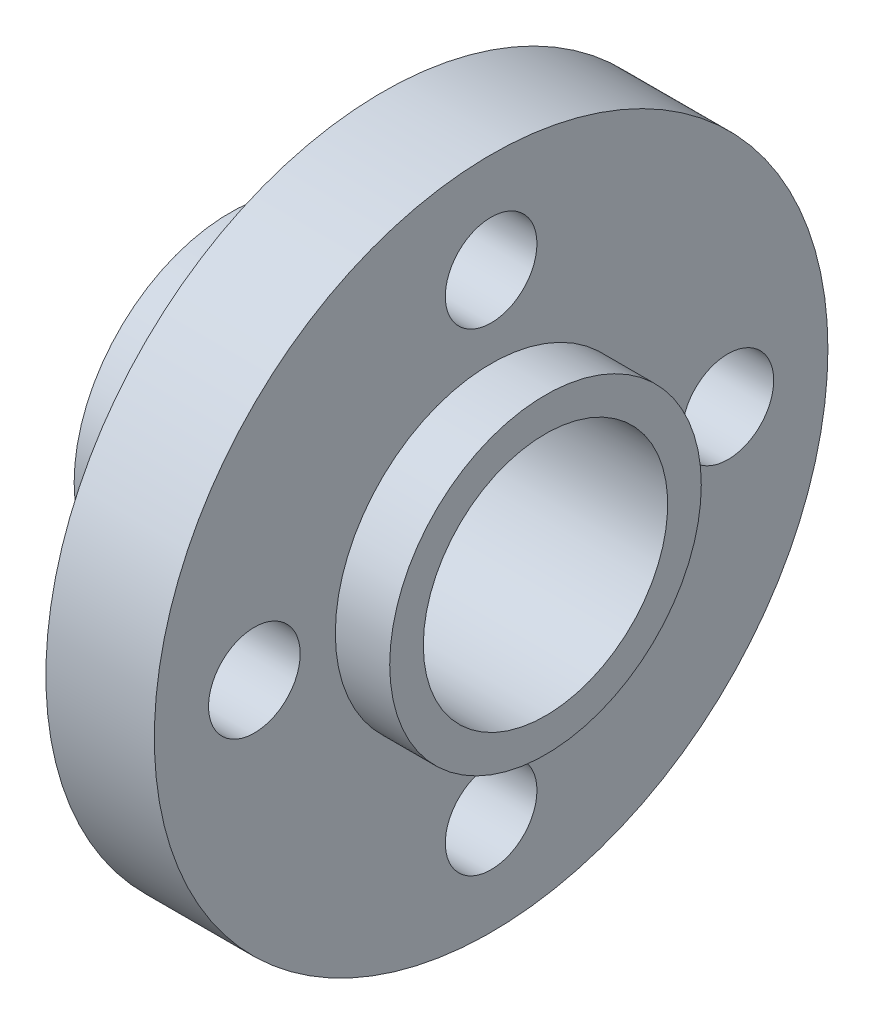
from build123d import *

# Parameters (mm, degrees)
SKETCH1_R           = 11.025
BOSS_EXTRUDE1_DEPTH = 3.55
SKETCH2_R           = 5.1
BOSS_EXTRUDE2_DEPTH = 1.78
SKETCH3_R           = 5.1
BOSS_EXTRUDE3_DEPTH = 5
SKETCH5_R           = 4
CUT_EXTRUDE1_DEPTH  = 11.33
SKETCH6_R           = 1.5
CUT_EXTRUDE2_DEPTH  = 6.33
CIRPATTERN1_COUNT   = 4


with BuildPart() as part:
    # Sketch1 → Boss-Extrude1 (new body)
    with BuildSketch(Plane(origin=(0, 0, 0), x_dir=(0, 0, -1), z_dir=(1, 0, 0))):
        Circle(SKETCH1_R)
    extrude(amount=BOSS_EXTRUDE1_DEPTH)

    # Sketch2 → Boss-Extrude2 (add)
    with BuildSketch(Plane(origin=(3.55, 0, 0), x_dir=(0, 0, -1), z_dir=(1, 0, 0))):
        Circle(SKETCH2_R)
    extrude(amount=BOSS_EXTRUDE2_DEPTH)

    # Sketch3 → Boss-Extrude3 (add)
    with BuildSketch(Plane.ZY):
        Circle(SKETCH3_R)
    extrude(amount=BOSS_EXTRUDE3_DEPTH)

    # Sketch5 → Cut-Extrude1 (cut, through all)
    with BuildSketch(Plane.ZY.offset(5)):
        Circle(SKETCH5_R)
    extrude(amount=-CUT_EXTRUDE1_DEPTH, mode=Mode.SUBTRACT)

    # Sketch6 → Cut-Extrude2 (cut, through all)
    with BuildSketch(Plane.ZY):
        with Locations((-7.75, 0)):
            Circle(SKETCH6_R)
    cut_extrude2 = extrude(amount=-CUT_EXTRUDE2_DEPTH, mode=Mode.SUBTRACT)

    # CirPattern1: Cut-Extrude2 ×4 about axis
    cirpattern1_axis = Axis((0, 0, 0), (1, 0, 0))
    for i in range(1, CIRPATTERN1_COUNT):
        add(cut_extrude2.rotate(cirpattern1_axis, i * 360 / CIRPATTERN1_COUNT), mode=Mode.SUBTRACT)


solid = part.part
